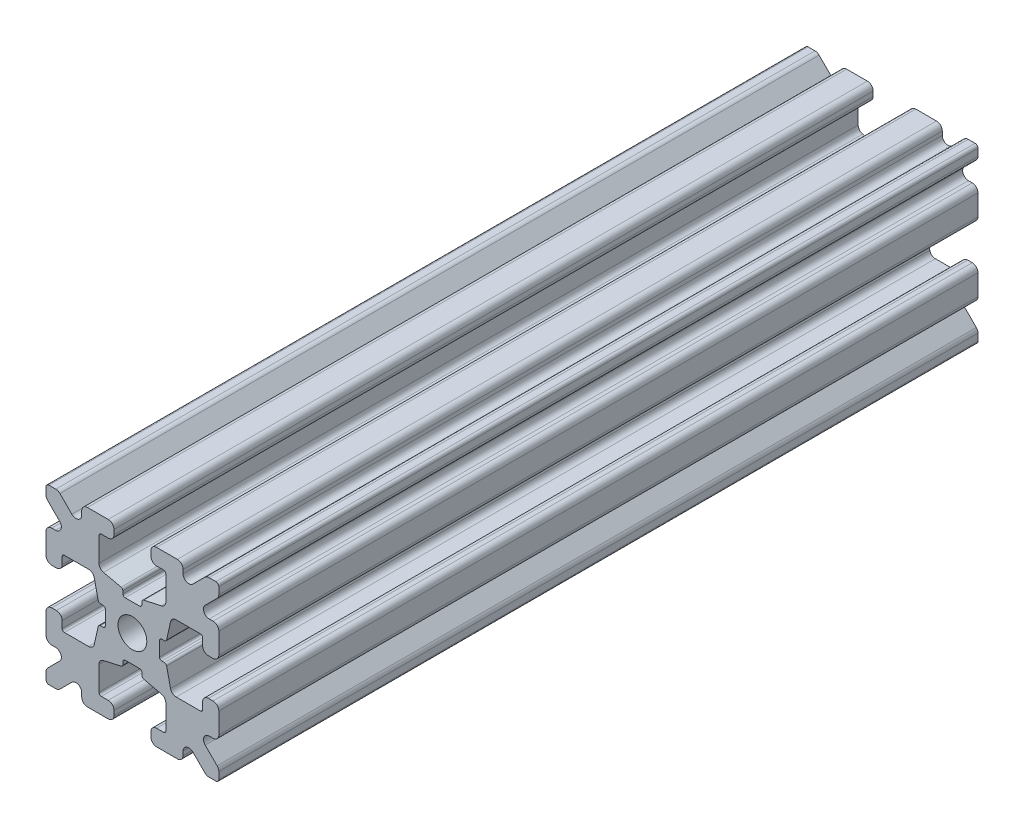
from build123d import *

# Parameters (mm, degrees)
SKETCH1_W           = 15
SKETCH1_H           = 15
SKETCH1_R           = 1.25
BOSS_EXTRUDE1_DEPTH = 32.95
FILLET1_R           = 0.25
CUT_EXTRUDE1_DEPTH  = 66.9
CUT_EXTRUDE3_DEPTH  = 66.9
FILLET3_R           = 0.5
FILLET4_R           = 0.5
FILLET5_R           = 3
FILLET6_R           = 0.2
CUT_EXTRUDE4_DEPTH  = 66.9
FILLET8_R           = 0.5
SKETCH6_W           = 5.1529354
SKETCH6_H           = 1.651
SKETCH6_W_2         = 1.651
SKETCH6_H_2         = 5.1529354
CUT_EXTRUDE5_DEPTH  = 66.9
FILLET10_R          = 0.2


with BuildPart() as part:
    # Sketch1 → Boss-Extrude1 (new body, symmetric)
    with BuildSketch(Plane.XY):
        Rectangle(SKETCH1_W, SKETCH1_H)
        Circle(SKETCH1_R, mode=Mode.SUBTRACT)
    extrude(amount=BOSS_EXTRUDE1_DEPTH, both=True)

    # Fillet1
    fillet1_edges = [part.edges().sort_by_distance(p)[0] for p in [
        (7.5, -7.5, 0),
        (-7.5, -7.5, 0),
        (-7.5, 7.5, 0),
        (7.5, 7.5, 0),
    ]]
    fillet(fillet1_edges, radius=FILLET1_R)

    # Sketch2 → Cut-Extrude1 (cut, through all)
    with BuildSketch(Plane.XY.offset(32.95)):
        Polygon((-7.5, 1.6), (-6.1, 1.6), (-6.1, 2.9), (-3.4, 2.9), (-3.4, -2.9), (-6.1, -2.9), (-6.1, -1.6), (-7.5, -1.6), align=None)
        Polygon((2.9, 6.1), (1.6, 6.1), (1.6, 7.5), (-1.6, 7.5), (-1.6, 6.1), (-2.9, 6.1), (-2.9, 3.4), (2.9, 3.4), align=None)
        Polygon((-1.6, -7.5), (-1.6, -6.1), (-2.9, -6.1), (-2.9, -3.4), (2.9, -3.4), (2.9, -6.1), (1.6, -6.1), (1.6, -7.5), align=None)
        Polygon((6.1, -2.9), (6.1, -1.6), (7.5, -1.6), (7.5, 1.6), (6.1, 1.6), (6.1, 2.9), (3.4, 2.9), (3.4, -2.9), align=None)
    extrude(amount=-CUT_EXTRUDE1_DEPTH, mode=Mode.SUBTRACT)

    # Sketch4 → Cut-Extrude3 (cut, through all)
    with BuildSketch(Plane.XY.offset(32.95)):
        Polygon((-3.4, 2.9), (-2.75, 0), (-3.4, -2.9), align=None)
        Polygon((-2.9, 3.4), (0, 2.75), (2.9, 3.4), align=None)
        Polygon((3.4, 2.9), (2.75, 0), (3.4, -2.9), align=None)
        Polygon((-2.9, -3.4), (0, -2.75), (2.9, -3.4), align=None)
    extrude(amount=-CUT_EXTRUDE3_DEPTH, mode=Mode.SUBTRACT)

    # Fillet3
    fillet3_edges = [part.edges().sort_by_distance(p)[0] for p in [
        (1.6, -7.5, 0),
        (-1.6, -7.5, 0),
        (-1.6, -6.1, 0),
        (1.6, -6.1, 0),
        (6.1, 1.6, 0),
        (7.5, 1.6, 0),
        (7.5, -1.6, 0),
        (6.1, -1.6, 0),
        (-7.5, -1.6, 0),
        (-7.5, 1.6, 0),
        (-6.1, 1.6, 0),
        (-6.1, -1.6, 0),
        (-1.6, 6.1, 0),
        (-1.6, 7.5, 0),
        (1.6, 7.5, 0),
        (1.6, 6.1, 0),
    ]]
    fillet(fillet3_edges, radius=FILLET3_R)

    # Fillet4
    fillet4_edges = [part.edges().sort_by_distance(p)[0] for p in [
        (-2.9, -3.4, 0),
        (2.9, -3.4, 0),
        (3.4, -2.9, 0),
        (3.4, 2.9, 0),
        (-3.4, 2.9, 0),
        (-3.4, -2.9, 0),
        (2.9, 3.4, 0),
        (-2.9, 3.4, 0),
    ]]
    fillet(fillet4_edges, radius=FILLET4_R)

    # Fillet5
    fillet5_edges = [part.edges().sort_by_distance(p)[0] for p in [
        (-2.75, 0, 0),
        (0, 2.75, 0),
        (2.75, 0, 0),
        (0, -2.75, 0),
    ]]
    fillet(fillet5_edges, radius=FILLET5_R)

    # Fillet6
    fillet6_edges = [part.edges().sort_by_distance(p)[0] for p in [
        (-2.9, -6.1, 0),
        (2.9, -6.1, 0),
        (6.1, -2.9, 0),
        (6.1, 2.9, 0),
        (-6.1, 2.9, 0),
        (-6.1, -2.9, 0),
        (2.9, 6.1, 0),
        (-2.9, 6.1, 0),
    ]]
    fillet(fillet6_edges, radius=FILLET6_R)

    # Sketch5 → Cut-Extrude4 (cut, through all)
    with BuildSketch(Plane.XY.offset(32.95)):
        Polygon((-7.5, 6.439339828), (-5.460660172, 4.4), (-7.5, 4.4), align=None)
        Polygon((-6.439339828, 7.5), (-4.4, 5.460660172), (-4.4, 7.5), align=None)
        Polygon((4.4, 7.5), (6.439339828, 7.5), (4.4, 5.460660172), align=None)
        Polygon((7.5, 6.439339828), (7.5, 4.4), (5.460660172, 4.4), align=None)
        Polygon((7.5, -6.439339828), (5.460660172, -4.4), (7.5, -4.4), align=None)
        Polygon((6.439339828, -7.5), (4.4, -5.460660172), (4.4, -7.5), align=None)
        Polygon((-4.4, -7.5), (-6.439339828, -7.5), (-4.4, -5.460660172), align=None)
        Polygon((-7.5, -6.439339828), (-7.5, -4.4), (-5.460660172, -4.4), align=None)
    extrude(amount=-CUT_EXTRUDE4_DEPTH, mode=Mode.SUBTRACT)

    # Fillet8
    fillet8_edges = [part.edges().sort_by_distance(p)[0] for p in [
        (-7.5, 4.4, 0),
        (-7.5, 6.439339828, 0),
        (-5.460660172, 4.4, 0),
        (7.5, -4.4, 0),
        (7.5, -6.439339828, 0),
        (5.460660172, -4.4, 0),
        (5.460660172, 4.4, 0),
        (7.5, 6.439339828, 0),
        (7.5, 4.4, 0),
        (-4.4, 7.5, 0),
        (-4.4, 5.460660172, 0),
        (-6.439339828, 7.5, 0),
        (-5.460660172, -4.4, 0),
        (-7.5, -6.439339828, 0),
        (-7.5, -4.4, 0),
        (4.4, 5.460660172, 0),
        (4.4, 7.5, 0),
        (6.439339828, 7.5, 0),
        (6.439339828, -7.5, 0),
        (4.4, -7.5, 0),
        (4.4, -5.460660172, 0),
        (-6.439339828, -7.5, 0),
        (-4.4, -5.460660172, 0),
        (-4.4, -7.5, 0),
    ]]
    fillet(fillet8_edges, radius=FILLET8_R)

    # Sketch6 → Cut-Extrude5 (cut, through all)
    with BuildSketch(Plane.XY.offset(32.95)):
        with Locations((4.9235323, 0)):
            Rectangle(SKETCH6_W, SKETCH6_H)
        with Locations((0, -4.9235323)):
            Rectangle(SKETCH6_W_2, SKETCH6_H_2)
        with Locations((-4.9235323, 0)):
            Rectangle(SKETCH6_W, SKETCH6_H)
        with Locations((0, 4.9235323)):
            Rectangle(SKETCH6_W_2, SKETCH6_H_2)
    extrude(amount=-CUT_EXTRUDE5_DEPTH, mode=Mode.SUBTRACT)

    # Fillet10
    fillet10_edges = [part.edges().sort_by_distance(p)[0] for p in [
        (0.8255, -2.935025862, 0),
        (-0.8255, -2.935025862, 0),
        (0.8255, -2.3470646, 0),
        (-0.8255, -2.3470646, 0),
        (2.935025862, 0.8255, 0),
        (2.935025862, -0.8255, 0),
        (2.3470646, 0.8255, 0),
        (2.3470646, -0.8255, 0),
        (-2.935025862, -0.8255, 0),
        (-2.935025862, 0.8255, 0),
        (-2.3470646, -0.8255, 0),
        (-2.3470646, 0.8255, 0),
        (-0.8255, 2.935025862, 0),
        (0.8255, 2.935025862, 0),
        (-0.8255, 2.3470646, 0),
        (0.8255, 2.3470646, 0),
    ]]
    fillet(fillet10_edges, radius=FILLET10_R)


solid = part.part
